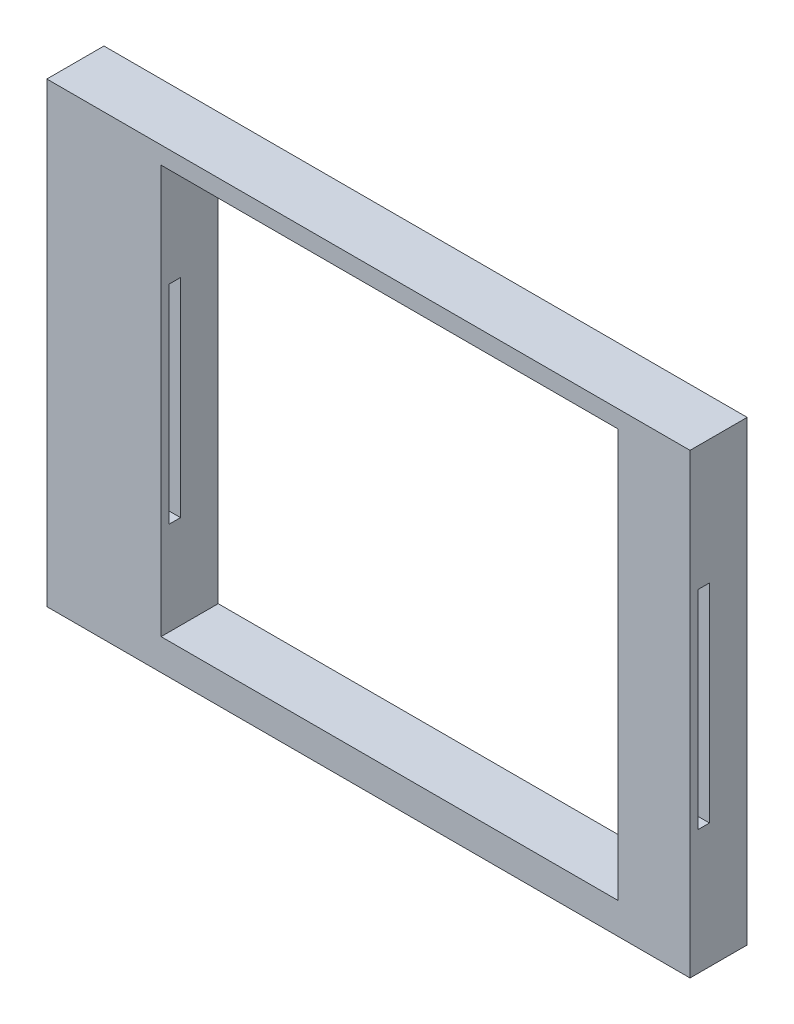
from build123d import *

# Parameters (mm, degrees)
SKETCH1_W               = 60
SKETCH1_H               = 40
BOSS_EXTRUDE1_DEPTH     = 5
CUT_EXTRUDE2_DEPTH      = 59.523499554
CUT_EXTRUDE2_DEPTH_BACK = 59.523499554
SKETCH2_W               = 1
SKETCH2_H               = 18.2
CUT_EXTRUDE3_DEPTH      = 7
SKETCH3_W               = 1
SKETCH3_H               = 18.2
CUT_EXTRUDE4_DEPTH      = 7
SKETCH6_W               = 40.00339764
SKETCH6_H               = 35.743622905
CUT_EXTRUDE5_DEPTH      = 7
SKETCH7_W               = 12.082118358
SKETCH7_H               = 49.934440021
CUT_EXTRUDE6_DEPTH      = 7


with BuildPart() as part:
    # Sketch1 → Boss-Extrude1 (new body)
    with BuildSketch(Plane.XY):
        with Locations((3.193565597, 28.20003109)):
            Rectangle(SKETCH1_W, SKETCH1_H)
    extrude(amount=BOSS_EXTRUDE1_DEPTH)

    # 3DSketch1 → Cut-Extrude2 (cut, two sides)
    with BuildSketch(Plane(origin=(-16.806434403, 18.20003109, 5), x_dir=(0.8944271909999159, 0.4472135954999582, 0), z_dir=(0, 0, 1))) as cut_extrude2_sk:
        Polygon((0, 0), (35.77708764, -17.88854382), (44.72135955, 0), (8.94427191, 17.88854382), align=None)
    extrude(amount=CUT_EXTRUDE2_DEPTH, mode=Mode.SUBTRACT)
    extrude(cut_extrude2_sk.sketch, amount=-CUT_EXTRUDE2_DEPTH_BACK, mode=Mode.SUBTRACT)

    # Sketch2 → Cut-Extrude3 (cut)
    with BuildSketch(Plane(origin=(-16.806434403, 0, 0), x_dir=(0, 0, -1), z_dir=(1, 0, 0))):
        with Locations((-3.8, 28.20003109)):
            Rectangle(SKETCH2_W, SKETCH2_H)
    extrude(amount=-CUT_EXTRUDE3_DEPTH, mode=Mode.SUBTRACT)

    # Sketch3 → Cut-Extrude4 (cut)
    with BuildSketch(Plane.ZY.offset(-23.193565597)):
        with Locations((3.8, 28.20003109)):
            Rectangle(SKETCH3_W, SKETCH3_H)
    extrude(amount=-CUT_EXTRUDE4_DEPTH, mode=Mode.SUBTRACT)

    # Sketch6 → Cut-Extrude5 (cut)
    with BuildSketch(Plane.XY.offset(5)):
        with Locations((3.195264417, 28.798257348)):
            Rectangle(SKETCH6_W, SKETCH6_H)
    extrude(amount=-CUT_EXTRUDE5_DEPTH, mode=Mode.SUBTRACT)

    # Sketch7 → Cut-Extrude6 (cut)
    with BuildSketch(Plane.XY.offset(5)):
        with Locations((35.534916951, 27.405939639)):
            Rectangle(SKETCH7_W, SKETCH7_H)
    extrude(amount=-CUT_EXTRUDE6_DEPTH, mode=Mode.SUBTRACT)


solid = part.part
